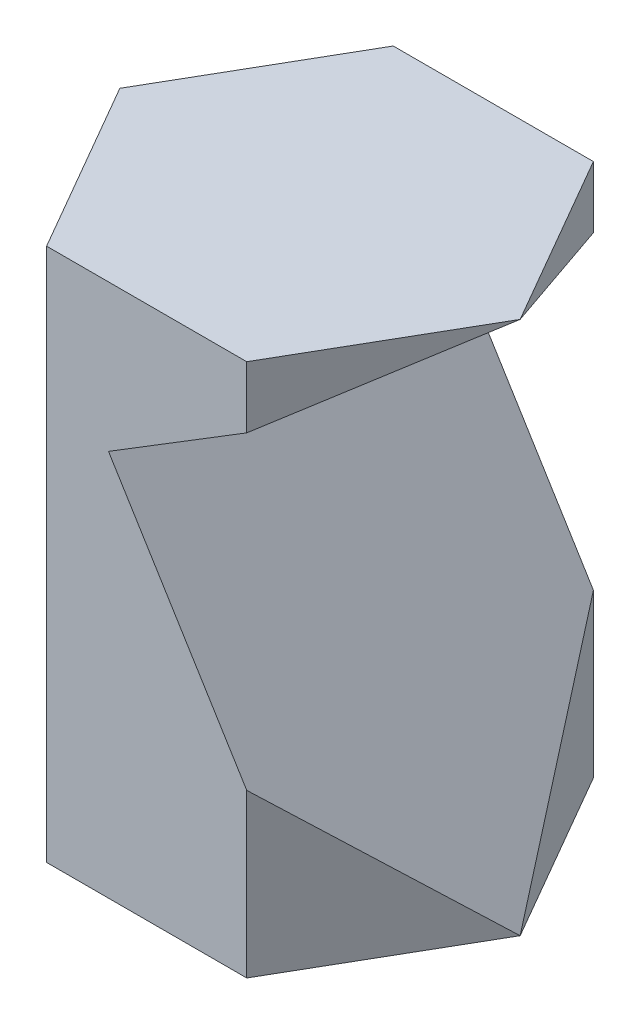
from build123d import *

# Parameters (mm, degrees)
BOSS_EXTRUDE1_DEPTH = 80
CUT_EXTRUDE2_DEPTH  = 62.961524227


with BuildPart() as part:
    # Sketch1 → Boss-Extrude1 (new body)
    with BuildSketch(Plane(origin=(0, 0, 0), x_dir=(1, 0, 0), z_dir=(0, 1, 0))):
        Polygon((45, -61.961524227), (60, -35.980762114), (45, -10), (15, -10), (0, -35.980762114), (15, -61.961524227), align=None)
    extrude(amount=BOSS_EXTRUDE1_DEPTH)

    # Sketch2 → Cut-Extrude2 (cut, through all)
    with BuildSketch(Plane.XY):
        Polygon((60, 80), (24.278857801, 58), (60, 0), (95.721142199, 22), align=None)
    extrude(amount=CUT_EXTRUDE2_DEPTH, mode=Mode.SUBTRACT)


solid = part.part
